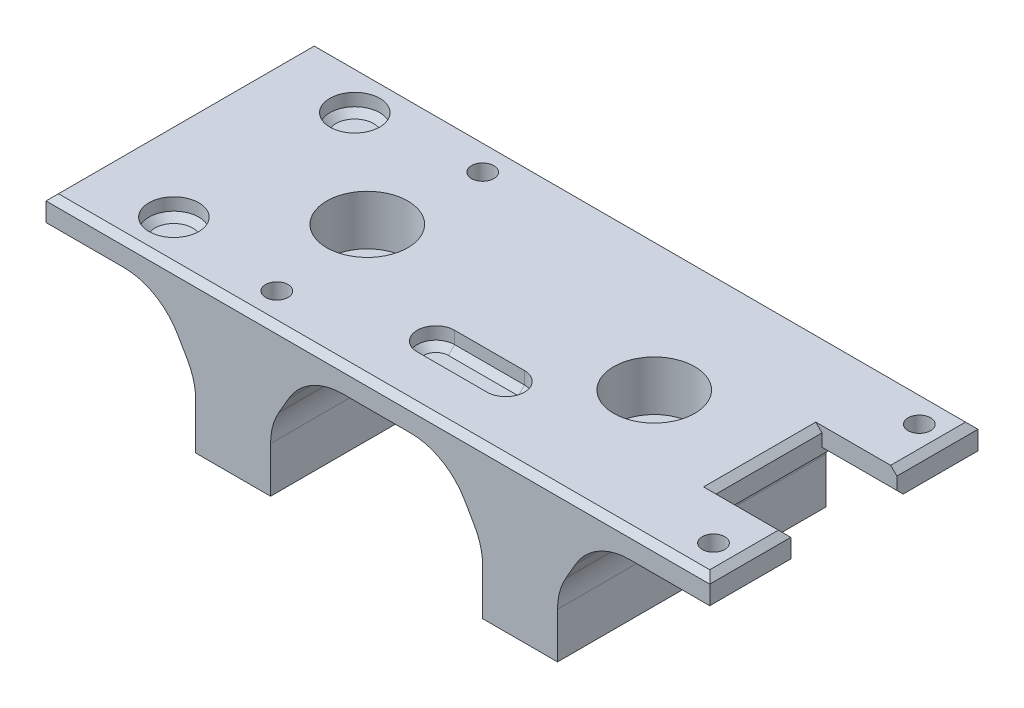
from build123d import *

# Parameters (mm, degrees)
SKETCH1_W                                   = 53.2
SKETCH1_H                                   = 21.5
BOSS_EXTRUDE1_DEPTH                         = 12
SKETCH2_R                                   = 0.9
CUT_EXTRUDE1_DEPTH                          = 5
SKETCH3_W                                   = 6
SKETCH3_H                                   = 8.5
CUT_EXTRUDE2_DEPTH                          = 13
SKETCH5_R                                   = 2
CUT_EXTRUDE3_DEPTH                          = 1.5
CBORE_FOR_M3_CHEESE_HEAD_SCREW1_D           = 3.4
CBORE_FOR_M3_CHEESE_HEAD_SCREW1_CBORE_D     = 6.5
CBORE_FOR_M3_CHEESE_HEAD_SCREW1_CBORE_DEPTH = 4
CUT_EXTRUDE4_DEPTH                          = 22.5
FILLET1_R                                   = 5
CHAMFER2_SIZE                               = 0.5
CHAMFER3_SIZE                               = 0.5


with BuildPart() as part:
    # Sketch1 → Boss-Extrude1 (new body)
    with BuildSketch(Plane(origin=(0, 0, 0), x_dir=(1, 0, 0), z_dir=(0, 1, 0))):
        Rectangle(SKETCH1_W, SKETCH1_H)
    extrude(amount=BOSS_EXTRUDE1_DEPTH)

    # Sketch2 → Cut-Extrude1 (cut)
    with BuildSketch(Plane(origin=(0, 12, 0), x_dir=(1, 0, 0), z_dir=(0, 1, 0))):
        with Locations((24.4, 8.25)):
            Circle(SKETCH2_R)
        with Locations((24.4, -8.25)):
            Circle(SKETCH2_R)
        with Locations((-10.6, -8.25)):
            Circle(SKETCH2_R)
        with Locations((-10.6, 8.25)):
            Circle(SKETCH2_R)
    extrude(amount=-CUT_EXTRUDE1_DEPTH, mode=Mode.SUBTRACT)

    # Sketch3 → Cut-Extrude2 (cut, through all)
    with BuildSketch(Plane.XZ):
        with Locations((23.6, 0)):
            Rectangle(SKETCH3_W, SKETCH3_H)
    extrude(amount=-CUT_EXTRUDE2_DEPTH, mode=Mode.SUBTRACT)

    # Sketch5 → Cut-Extrude3 (cut)
    with BuildSketch(Plane(origin=(0, 12, 0), x_dir=(1, 0, 0), z_dir=(0, 1, 0))):
        with Locations((-19.85, 7.25)):
            Circle(SKETCH5_R)
        with Locations((-19.85, -7.25)):
            Circle(SKETCH5_R)
        with BuildLine():
            Line((-0.75, -3.85), (4.85, -3.85))
            ThreePointArc((4.85, -3.85), (6.35, -5.35), (4.85, -6.85))
            Line((4.85, -6.85), (-0.75, -6.85))
            ThreePointArc((-0.75, -6.85), (-2.25, -5.35), (-0.75, -3.85))
        make_face()
    extrude(amount=-CUT_EXTRUDE3_DEPTH, mode=Mode.SUBTRACT)

    # CBORE for M3 Cheese Head Screw1 (through all)
    with Locations(Plane(origin=(-11.6, 12, 0), x_dir=(0, 0, 1), z_dir=(0, 1, 0))):
        with Locations((0, 0), (0, 23)):
            CounterBoreHole(CBORE_FOR_M3_CHEESE_HEAD_SCREW1_D / 2, CBORE_FOR_M3_CHEESE_HEAD_SCREW1_CBORE_D / 2, CBORE_FOR_M3_CHEESE_HEAD_SCREW1_CBORE_DEPTH)

    # Sketch9 → Cut-Extrude4 (cut, through all)
    with BuildSketch(Plane.XY.offset(10.75)):
        Polygon((-17.486751346, 10), (-26.6, 10), (-26.6, 0), (-14.6, 0), (-14.6, 5), align=None)
        Polygon((5.513248654, 10), (-5.713248654, 10), (-8.6, 5), (-8.6, 0), (8.4, 0), (8.4, 5), align=None)
        Polygon((26.6, 0), (26.6, 10), (17.286751346, 10), (14.4, 5), (14.4, 0), align=None)
    extrude(amount=-CUT_EXTRUDE4_DEPTH, mode=Mode.SUBTRACT)

    # Fillet1
    fillet1_edges = [part.edges().sort_by_distance(p)[0] for p in [
        (-14.6, 5, 0),
        (-17.486751346, 10, 0),
        (8.4, 5, 0),
        (-8.6, 5, 0),
        (-5.713248654, 10, 0),
        (5.513248654, 10, 0),
        (17.286751346, 10, 0),
        (14.4, 5, 0),
    ]]
    fillet(fillet1_edges, radius=FILLET1_R)

    # Chamfer2
    chamfer2_edges = [part.edges().sort_by_distance(p)[0] for p in [
        (-11.5, 7, -8.25),
        (-11.5, 7, 8.25),
        (-2.25, 10.5, 5.35),
        (2.05, 10.5, 3.85),
        (6.35, 10.5, 5.35),
        (2.05, 10.5, 6.85),
        (-21.85, 10.5, 7.25),
        (-21.85, 10.5, -7.25),
        (11.4, 8, 1.7),
        (-11.6, 8, 1.7),
    ]]
    chamfer(chamfer2_edges, length=CHAMFER2_SIZE)

    # Chamfer3
    chamfer3_edges = [part.edges().sort_by_distance(p)[0] for p in [
        (-26.6, 12, 0),
        (23.6, 10, -4.25),
        (0, 12, 10.75),
        (26.6, 12, -7.5),
        (20.6, 12, 0),
        (23.6, 12, 4.25),
        (26.6, 12, 7.5),
        (0, 12, -10.75),
    ]]
    chamfer(chamfer3_edges, length=CHAMFER3_SIZE)


solid = part.part
